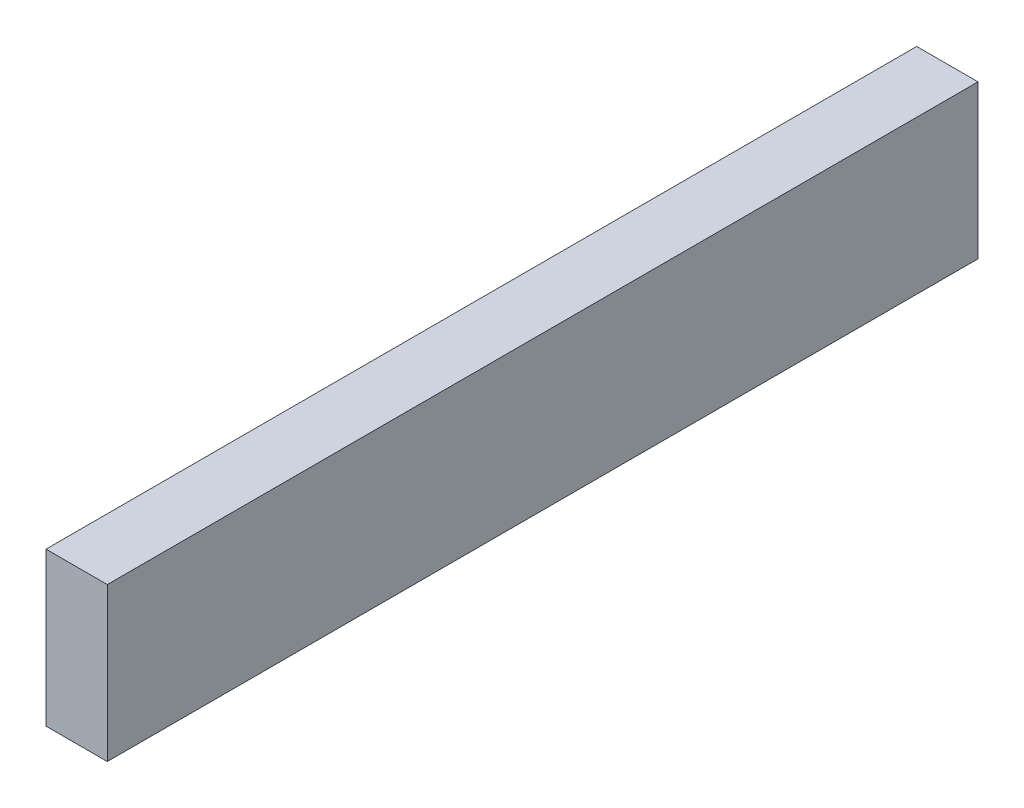
from build123d import *

# Parameters (mm, degrees)
SKETCH1_W           = 100
SKETCH1_H           = 250
BOSS_EXTRUDE1_DEPTH = 1420


with BuildPart() as part:
    # Sketch1 → Boss-Extrude1 (new body)
    with BuildSketch(Plane.XY):
        with Locations((50, 125)):
            Rectangle(SKETCH1_W, SKETCH1_H)
    extrude(amount=BOSS_EXTRUDE1_DEPTH)


solid = part.part
